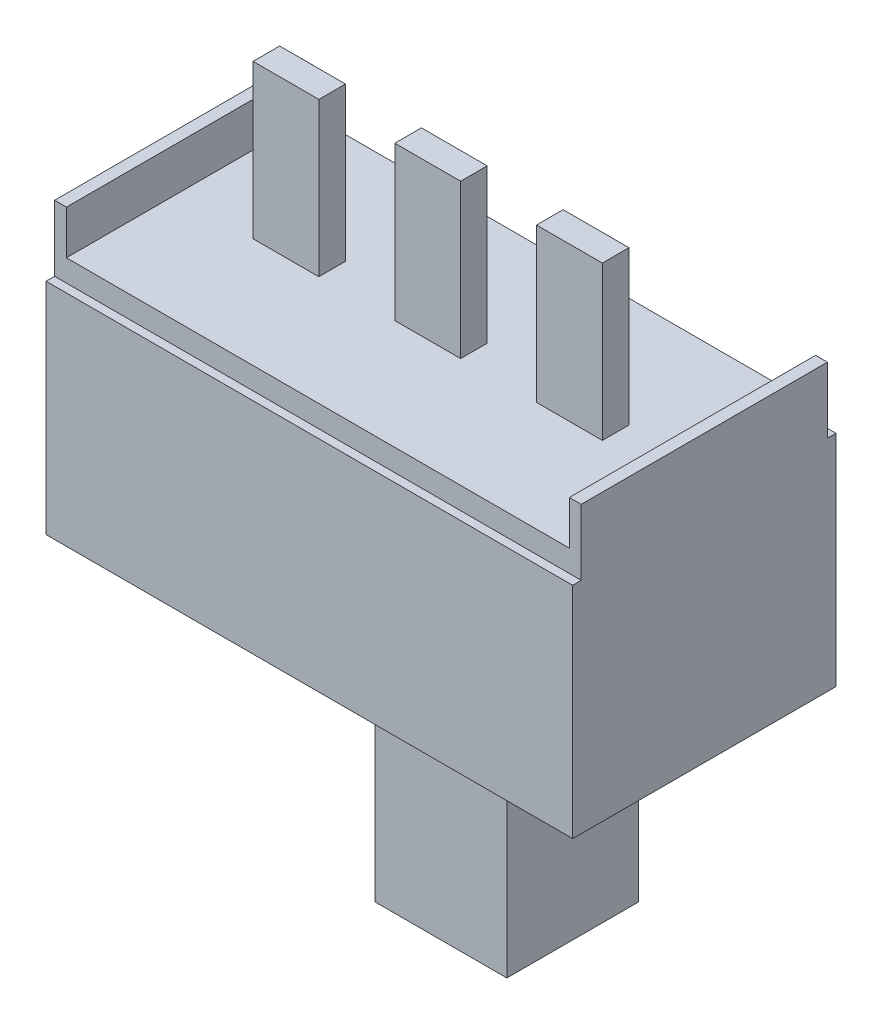
from build123d import *

# Parameters (mm, degrees)
SKETCH_1_W      = 12
SKETCH_1_H      = 6
SKETCH_1_W_2    = 6
SKETCH_1_H_2    = 3
EXTRUDE_1_DEPTH = 5
SKETCH_2_W      = 11.46002803
SKETCH_2_H      = 5.61022278
SKETCH_2_W_2    = 1.5
SKETCH_2_H_2    = 0.606360044
EXTRUDE_2_DEPTH = 0.5
SKETCH_2_3_W    = 0.269985985
SKETCH_2_3_H    = 5.61022278
EXTRUDE_3_DEPTH = 1.5
SKETCH_2_4_W    = 1.5
SKETCH_2_4_H    = 0.606360044
EXTRUDE_4_DEPTH = 4
SKETCH_4_W      = 6
SKETCH_4_H      = 3
EXTRUDE_5_DEPTH = 4.5
SKETCH_6_W      = 3
SKETCH_6_H      = 3
EXTRUDE_6_DEPTH = 5.5


with BuildPart() as part:
    # 草图1 → 凸台-拉伸1 (new body)
    with BuildSketch(Plane(origin=(0, 0, 0), x_dir=(1, 0, 0), z_dir=(0, 1, 0))):
        Rectangle(SKETCH_1_W, SKETCH_1_H)
        Rectangle(SKETCH_1_W_2, SKETCH_1_H_2, mode=Mode.SUBTRACT)
    extrude(amount=EXTRUDE_1_DEPTH)

    # 草图2 → 凸台-拉伸2 (add)
    with BuildSketch(Plane(origin=(0, 5, 0), x_dir=(1, 0, 0), z_dir=(0, 1, 0))):
        Rectangle(SKETCH_2_W, SKETCH_2_H)
        with Locations((3.230014015, 0)):
            Rectangle(SKETCH_2_W_2, SKETCH_2_H_2, mode=Mode.SUBTRACT)
        with Locations((-3.230014015, 0)):
            Rectangle(SKETCH_2_W_2, SKETCH_2_H_2, mode=Mode.SUBTRACT)
        Rectangle(SKETCH_2_W_2, SKETCH_2_H_2, mode=Mode.SUBTRACT)
    extrude(amount=EXTRUDE_2_DEPTH)

    # 草图2<3> → 凸台-拉伸3 (add)
    with BuildSketch(Plane(origin=(0, 5, 0), x_dir=(1, 0, 0), z_dir=(0, 1, 0))):
        with Locations((5.865007008, 0)):
            Rectangle(SKETCH_2_3_W, SKETCH_2_3_H)
        with Locations((-5.865007008, 0)):
            Rectangle(SKETCH_2_3_W, SKETCH_2_3_H)
    extrude(amount=EXTRUDE_3_DEPTH)

    # 草图2<4> → 凸台-拉伸4 (add)
    with BuildSketch(Plane(origin=(0, 5, 0), x_dir=(1, 0, 0), z_dir=(0, 1, 0))):
        with Locations((3.230014015, 0)):
            Rectangle(SKETCH_2_4_W, SKETCH_2_4_H)
        Rectangle(SKETCH_2_4_W, SKETCH_2_4_H)
        with Locations((-3.230014015, 0)):
            Rectangle(SKETCH_2_4_W, SKETCH_2_4_H)
    extrude(amount=EXTRUDE_4_DEPTH)

    # 草图4 → 凸台-拉伸5 (add)
    with BuildSketch(Plane.XZ.offset(-5)):
        Rectangle(SKETCH_4_W, SKETCH_4_H)
    extrude(amount=EXTRUDE_5_DEPTH)

    # 草图6 → 凸台-拉伸6 (add)
    with BuildSketch(Plane.XZ.offset(-0.5)):
        with Locations((1.5, 0)):
            Rectangle(SKETCH_6_W, SKETCH_6_H)
    extrude(amount=EXTRUDE_6_DEPTH)


solid = part.part
